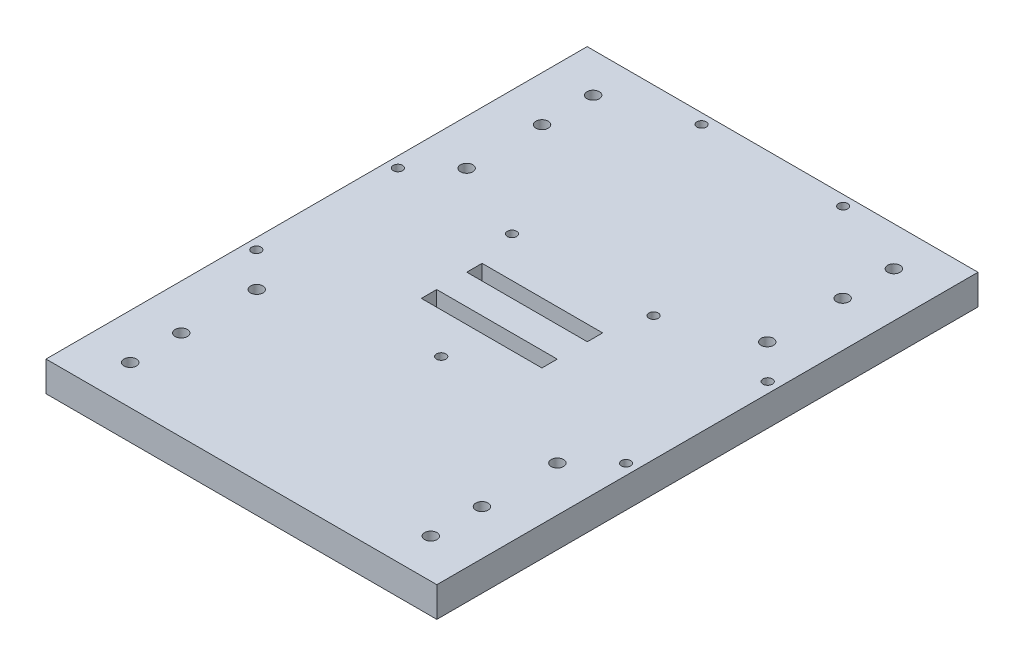
from build123d import *

# Parameters (mm, degrees)
SKETCH1_W               = 65
SKETCH1_H               = 90
SKETCH1_R               = 2.05
BOSS_EXTRUDE1_DEPTH     = 10
MIRROR2_COPY_1_SKETCH_W = 65
MIRROR2_COPY_1_SKETCH_H = 90
MIRROR2_COPY_1_SKETCH_R = 2.05
MIRROR2_COPY_1_DEPTH    = 10
SKETCH2_W               = 40.1
SKETCH2_H               = 5.1
CUT_EXTRUDE1_DEPTH      = 10
SKETCH3_R               = 1.55
CUT_EXTRUDE2_DEPTH      = 10


with BuildPart() as part:
    # Sketch1 → Boss-Extrude1 (new body)
    with BuildSketch(Plane(origin=(0, 0, 0), x_dir=(1, 0, 0), z_dir=(0, 1, 0))):
        with Locations((-32.5, 45)):
            Rectangle(SKETCH1_W, SKETCH1_H)
        with Locations((-50, 77)):
            Circle(SKETCH1_R, mode=Mode.SUBTRACT)
        with Locations((-50, 34.9)):
            Circle(SKETCH1_R, mode=Mode.SUBTRACT)
        with Locations((-50, 60)):
            Circle(SKETCH1_R, mode=Mode.SUBTRACT)
    boss_extrude1 = extrude(amount=BOSS_EXTRUDE1_DEPTH)

    # Mirror1: Boss-Extrude1 across Right Plane
    add(boss_extrude1.mirror(Plane(origin=(0, 0, 0), x_dir=(0, 0, -1), z_dir=(1, 0, 0))))

    # Mirror2: Boss-Extrude1 across Front Plane
    add(boss_extrude1.mirror(Plane.XY))

    # Mirror2 copy 1 sketch → Mirror2 copy 1 (add)
    with BuildSketch(Plane(origin=(0, 0, 0), x_dir=(-1, 0, 0), z_dir=(0, 1, 0))):
        with Locations((-32.5, 45)):
            Rectangle(MIRROR2_COPY_1_SKETCH_W, MIRROR2_COPY_1_SKETCH_H)
        with Locations((-50, 77)):
            Circle(MIRROR2_COPY_1_SKETCH_R, mode=Mode.SUBTRACT)
        with Locations((-50, 34.9)):
            Circle(MIRROR2_COPY_1_SKETCH_R, mode=Mode.SUBTRACT)
        with Locations((-50, 60)):
            Circle(MIRROR2_COPY_1_SKETCH_R, mode=Mode.SUBTRACT)
    extrude(amount=MIRROR2_COPY_1_DEPTH)

    # Sketch2 → Cut-Extrude1 (cut)
    with BuildSketch(Plane(origin=(0, 10, 0), x_dir=(1, 0, 0), z_dir=(0, 1, 0))):
        with Locations((0, 7.55)):
            Rectangle(SKETCH2_W, SKETCH2_H)
        with Locations((0, -7.55)):
            Rectangle(SKETCH2_W, SKETCH2_H)
    extrude(amount=-CUT_EXTRUDE1_DEPTH, mode=Mode.SUBTRACT)

    # Sketch3 → Cut-Extrude2 (cut)
    with BuildSketch(Plane(origin=(0, 10, 0), x_dir=(1, 0, 0), z_dir=(0, 1, 0))):
        with Locations((-23.55, 86.6)):
            Circle(SKETCH3_R)
        with Locations((-23.55, 23.55)):
            Circle(SKETCH3_R)
        with Locations((-61.5, 23.55)):
            Circle(SKETCH3_R)
        with Locations((23.55, 23.55)):
            Circle(SKETCH3_R)
        with Locations((23.55, 86.6)):
            Circle(SKETCH3_R)
        with Locations((61.5, 23.55)):
            Circle(SKETCH3_R)
        with Locations((-61.5, -23.55)):
            Circle(SKETCH3_R)
        with Locations((0, -23.55)):
            Circle(SKETCH3_R)
        with Locations((61.5, -23.55)):
            Circle(SKETCH3_R)
    extrude(amount=-CUT_EXTRUDE2_DEPTH, mode=Mode.SUBTRACT)


solid = part.part
